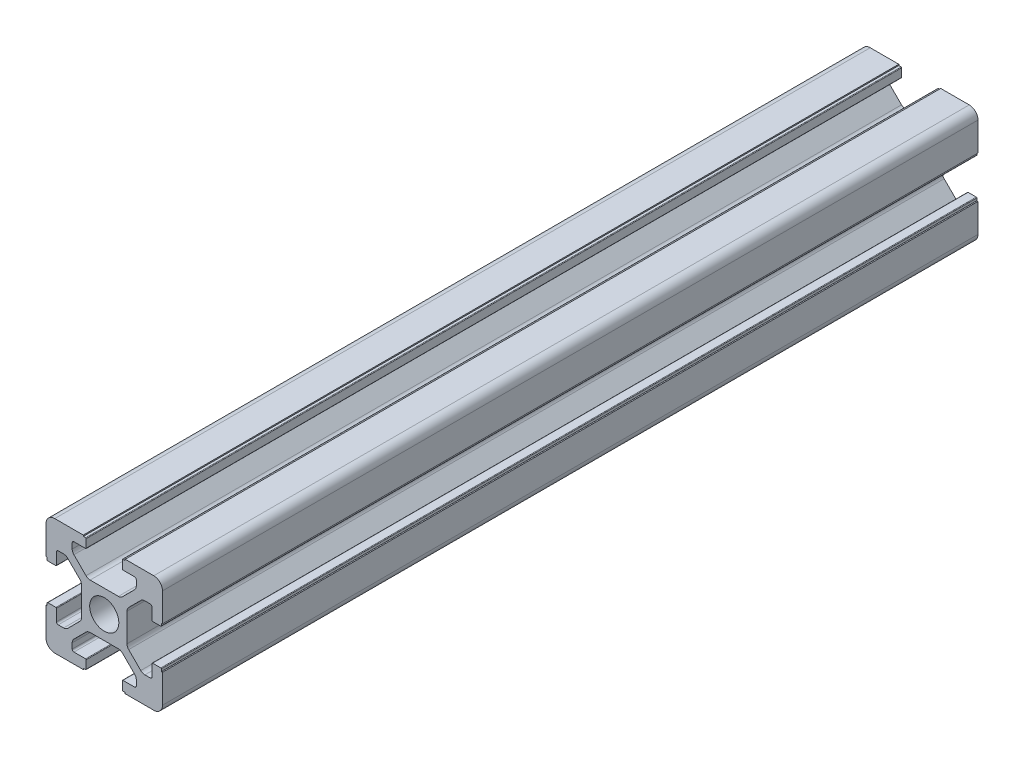
from build123d import *

# Parameters (mm, degrees)
SKETCH_1_R      = 2.5
EXTRUDE_1_DEPTH = 140
FILLET_1_R      = 1.5


with BuildPart() as part:
    # 草图1 → 凸台-拉伸1 (new body)
    with BuildSketch(Plane.XY):
        with BuildLine():
            Line((20, 13.6), (20, 20))
            Line((20, 20), (13.6, 20))
            Line((13.6, 20), (13.6, 19.8))
            Line((13.6, 19.8), (13.2, 19.8))
            ThreePointArc((13.2, 19.8), (13.129289322, 19.770710678), (13.1, 19.7))
            Line((13.1, 19.7), (13.1, 18.3))
            ThreePointArc((13.1, 18.3), (13.129289322, 18.229289322), (13.2, 18.2))
            Line((13.2, 18.2), (15.2, 18.2))
            ThreePointArc((15.2, 18.2), (15.412132034, 18.112132034), (15.5, 17.9))
            Line((15.5, 17.9), (15.5, 16.974873734))
            ThreePointArc((15.5, 16.974873734), (15.423879533, 16.592190302), (15.207106781, 16.267766953))
            Line((15.207106781, 16.267766953), (13.132233047, 14.192893219))
            ThreePointArc((13.132233047, 14.192893219), (12.807809698, 13.976120467), (12.425126266, 13.9))
            Line((12.425126266, 13.9), (7.574873734, 13.9))
            ThreePointArc((7.574873734, 13.9), (7.192190302, 13.976120467), (6.867766953, 14.192893219))
            Line((6.867766953, 14.192893219), (4.792893219, 16.267766953))
            ThreePointArc((4.792893219, 16.267766953), (4.576120467, 16.592190302), (4.5, 16.974873734))
            Line((4.5, 16.974873734), (4.5, 17.9))
            ThreePointArc((4.5, 17.9), (4.587867966, 18.112132034), (4.8, 18.2))
            Line((4.8, 18.2), (6.8, 18.2))
            ThreePointArc((6.8, 18.2), (6.870710678, 18.229289322), (6.9, 18.3))
            Line((6.9, 18.3), (6.9, 19.7))
            ThreePointArc((6.9, 19.7), (6.870710678, 19.770710678), (6.8, 19.8))
            Line((6.8, 19.8), (6.4, 19.8))
            Line((6.4, 19.8), (6.4, 20))
            Line((6.4, 20), (0, 20))
            Line((0, 20), (0, 13.6))
            Line((0, 13.6), (0.2, 13.6))
            Line((0.2, 13.6), (0.2, 13.2))
            ThreePointArc((0.2, 13.2), (0.229289322, 13.129289322), (0.3, 13.1))
            Line((0.3, 13.1), (1.7, 13.1))
            ThreePointArc((1.7, 13.1), (1.770710678, 13.129289322), (1.8, 13.2))
            Line((1.8, 13.2), (1.8, 15.2))
            ThreePointArc((1.8, 15.2), (1.887867966, 15.412132034), (2.1, 15.5))
            Line((2.1, 15.5), (3.025126266, 15.5))
            ThreePointArc((3.025126266, 15.5), (3.407809698, 15.423879533), (3.732233047, 15.207106781))
            Line((3.732233047, 15.207106781), (5.807106781, 13.132233047))
            ThreePointArc((5.807106781, 13.132233047), (6.023879533, 12.807809698), (6.1, 12.425126266))
            Line((6.1, 12.425126266), (6.1, 7.574873734))
            ThreePointArc((6.1, 7.574873734), (6.023879533, 7.192190302), (5.807106781, 6.867766953))
            Line((5.807106781, 6.867766953), (3.732233047, 4.792893219))
            ThreePointArc((3.732233047, 4.792893219), (3.407809698, 4.576120467), (3.025126266, 4.5))
            Line((3.025126266, 4.5), (2.1, 4.5))
            ThreePointArc((2.1, 4.5), (1.887867966, 4.587867966), (1.8, 4.8))
            Line((1.8, 4.8), (1.8, 6.8))
            ThreePointArc((1.8, 6.8), (1.770710678, 6.870710678), (1.7, 6.9))
            Line((1.7, 6.9), (0.3, 6.9))
            ThreePointArc((0.3, 6.9), (0.229289322, 6.870710678), (0.2, 6.8))
            Line((0.2, 6.8), (0.2, 6.4))
            Line((0.2, 6.4), (0, 6.4))
            Line((0, 6.4), (0, 0))
            Line((0, 0), (6.4, 0))
            Line((6.4, 0), (6.4, 0.2))
            Line((6.4, 0.2), (6.8, 0.2))
            ThreePointArc((6.8, 0.2), (6.870710678, 0.229289322), (6.9, 0.3))
            Line((6.9, 0.3), (6.9, 1.7))
            ThreePointArc((6.9, 1.7), (6.870710678, 1.770710678), (6.8, 1.8))
            Line((6.8, 1.8), (4.8, 1.8))
            ThreePointArc((4.8, 1.8), (4.587867966, 1.887867966), (4.5, 2.1))
            Line((4.5, 2.1), (4.5, 3.025126266))
            ThreePointArc((4.5, 3.025126266), (4.576120467, 3.407809698), (4.792893219, 3.732233047))
            Line((4.792893219, 3.732233047), (6.867766953, 5.807106781))
            ThreePointArc((6.867766953, 5.807106781), (7.192190302, 6.023879533), (7.574873734, 6.1))
            Line((7.574873734, 6.1), (12.425126266, 6.1))
            ThreePointArc((12.425126266, 6.1), (12.807809698, 6.023879533), (13.132233047, 5.807106781))
            Line((13.132233047, 5.807106781), (15.207106781, 3.732233047))
            ThreePointArc((15.207106781, 3.732233047), (15.423879533, 3.407809698), (15.5, 3.025126266))
            Line((15.5, 3.025126266), (15.5, 2.1))
            ThreePointArc((15.5, 2.1), (15.412132034, 1.887867966), (15.2, 1.8))
            Line((15.2, 1.8), (13.2, 1.8))
            ThreePointArc((13.2, 1.8), (13.129289322, 1.770710678), (13.1, 1.7))
            Line((13.1, 1.7), (13.1, 0.3))
            ThreePointArc((13.1, 0.3), (13.129289322, 0.229289322), (13.2, 0.2))
            Line((13.2, 0.2), (13.6, 0.2))
            Line((13.6, 0.2), (13.6, 0))
            Line((13.6, 0), (20, 0))
            Line((20, 0), (20, 6.4))
            Line((20, 6.4), (19.8, 6.4))
            Line((19.8, 6.4), (19.8, 6.8))
            ThreePointArc((19.8, 6.8), (19.770710678, 6.870710678), (19.7, 6.9))
            Line((19.7, 6.9), (18.3, 6.9))
            ThreePointArc((18.3, 6.9), (18.229289322, 6.870710678), (18.2, 6.8))
            Line((18.2, 6.8), (18.2, 4.8))
            ThreePointArc((18.2, 4.8), (18.112132034, 4.587867966), (17.9, 4.5))
            Line((17.9, 4.5), (16.974873734, 4.5))
            ThreePointArc((16.974873734, 4.5), (16.592190302, 4.576120467), (16.267766953, 4.792893219))
            Line((16.267766953, 4.792893219), (14.192893219, 6.867766953))
            ThreePointArc((14.192893219, 6.867766953), (13.976120467, 7.192190302), (13.9, 7.574873734))
            Line((13.9, 7.574873734), (13.9, 12.425126266))
            ThreePointArc((13.9, 12.425126266), (13.976120467, 12.807809698), (14.192893219, 13.132233047))
            Line((14.192893219, 13.132233047), (16.267766953, 15.207106781))
            ThreePointArc((16.267766953, 15.207106781), (16.592190302, 15.423879533), (16.974873734, 15.5))
            Line((16.974873734, 15.5), (17.9, 15.5))
            ThreePointArc((17.9, 15.5), (18.112132034, 15.412132034), (18.2, 15.2))
            Line((18.2, 15.2), (18.2, 13.2))
            ThreePointArc((18.2, 13.2), (18.229289322, 13.129289322), (18.3, 13.1))
            Line((18.3, 13.1), (19.7, 13.1))
            ThreePointArc((19.7, 13.1), (19.770710678, 13.129289322), (19.8, 13.2))
            Line((19.8, 13.2), (19.8, 13.6))
            Line((19.8, 13.6), (20, 13.6))
        make_face()
        with Locations((10, 10)):
            Circle(SKETCH_1_R, mode=Mode.SUBTRACT)
    extrude(amount=EXTRUDE_1_DEPTH)

    # 圆角1
    fillet_1_edges = [part.edges().sort_by_distance(p)[0] for p in [
        (0, 0, 70),
        (0, 20, 70),
        (20, 20, 70),
        (20, 0, 70),
    ]]
    fillet(fillet_1_edges, radius=FILLET_1_R)


solid = part.part
